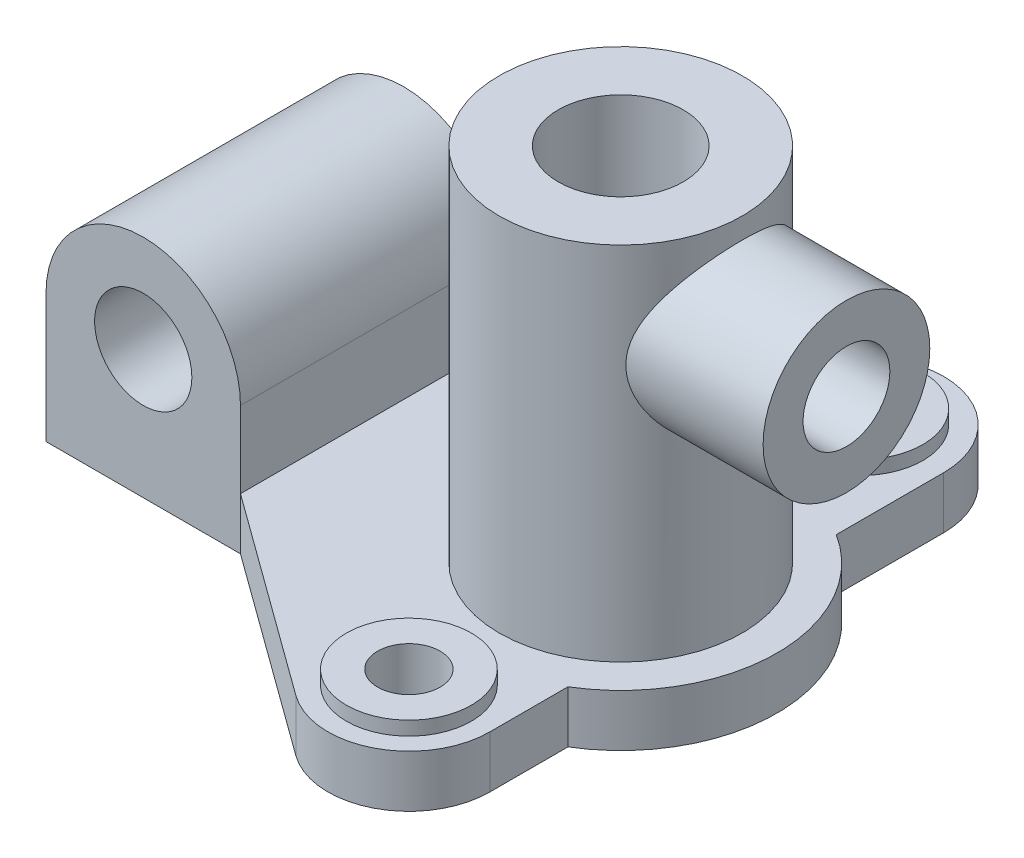
from build123d import *

# Parameters (mm, degrees)
SKETCH1_R               = 18
SKETCH1_R_2             = 35
BOSS_EXTRUDE1_DEPTH     = 15
SKETCH1_3_R             = 35
SKETCH1_3_R_2           = 18
BOSS_EXTRUDE2_DEPTH     = 119
SKETCH1_4_R             = 18
SKETCH1_4_R_2           = 9
BOSS_EXTRUDE3_DEPTH     = 19
SKETCH1_5_W             = 56
SKETCH1_5_H             = 75
BOSS_EXTRUDE4_DEPTH     = 65
CUT_EXTRUDE1_DEPTH      = 198.974745864
CUT_EXTRUDE1_DEPTH_BACK = 65
SKETCH2_R               = 14
SKETCH3_R               = 24
SKETCH3_R_2             = 12.5
BOSS_EXTRUDE5_DEPTH     = 65
SKETCH1_6_R             = 18
CUT_EXTRUDE3_DEPTH      = 263
SKETCH3_3_R             = 12.5
CUT_EXTRUDE4_DEPTH      = 263


with BuildPart() as part:
    # Sketch1 → Boss-Extrude1 (new body)
    with BuildSketch(Plane(origin=(0, 0, 0), x_dir=(1, 0, 0), z_dir=(0, 1, 0))):
        with BuildLine():
            ThreePointArc((23.30367726, -38.495955971), (44.998138968, -0.409254655), (24, 38.065732621))
            Line((24, 38.065732621), (24, 69))
            ThreePointArc((24, 69), (9.874292088, 90.874605271), (-15.87486298, 86.999686813))
            Line((-15.87486298, 86.999686813), (-72, 37.5))
            Line((-72, 37.5), (-72, -37.5))
            Line((-72, -37.5), (-13.696259751, -79.854013967))
            ThreePointArc((-13.696259751, -79.854013967), (10.58036287, -81.76336426), (23.30367726, -61))
            Line((23.30367726, -61), (23.30367726, -38.495955971))
        make_face()
        with Locations((0, -61)):
            Circle(SKETCH1_R, mode=Mode.SUBTRACT)
        Circle(SKETCH1_R_2, mode=Mode.SUBTRACT)
        with Locations((0, 69)):
            Circle(SKETCH1_R, mode=Mode.SUBTRACT)
    extrude(amount=BOSS_EXTRUDE1_DEPTH)

    # Sketch1_3 → Boss-Extrude2 (add)
    with BuildSketch(Plane(origin=(0, 0, 0), x_dir=(1, 0, 0), z_dir=(0, 1, 0))):
        Circle(SKETCH1_3_R)
        Circle(SKETCH1_3_R_2, mode=Mode.SUBTRACT)
    extrude(amount=BOSS_EXTRUDE2_DEPTH)

    # Sketch1_4 → Boss-Extrude3 (add)
    # profile 1 of 2: a face of its own
    with BuildSketch(Plane(origin=(0, 0, 0), x_dir=(1, 0, 0), z_dir=(0, 1, 0))):
        with Locations((0, 69)):
            Circle(SKETCH1_4_R)
        with Locations((0, 69)):
            Circle(SKETCH1_4_R_2, mode=Mode.SUBTRACT)
    # profile 2 of 2: a face of its own
    with BuildSketch(Plane(origin=(0, 0, 0), x_dir=(1, 0, 0), z_dir=(0, 1, 0))):
        with Locations((0, -61)):
            Circle(SKETCH1_4_R)
        with Locations((0, -61)):
            Circle(SKETCH1_4_R_2, mode=Mode.SUBTRACT)
    extrude(amount=BOSS_EXTRUDE3_DEPTH)

    # Sketch1_5 → Boss-Extrude4 (add)
    with BuildSketch(Plane(origin=(0, 0, 0), x_dir=(1, 0, 0), z_dir=(0, 1, 0))):
        with Locations((-100, 0)):
            Rectangle(SKETCH1_5_W, SKETCH1_5_H)
    extrude(amount=BOSS_EXTRUDE4_DEPTH)

    # Sketch2 → Cut-Extrude1 (cut, two sides: drawn at the far end of the back side and taken through both)
    with BuildSketch(Plane.XY.offset(-CUT_EXTRUDE1_DEPTH_BACK)):
        with BuildLine():
            Line((-128, 65), (-128, 37))
            ThreePointArc((-128, 37), (-119.798989873, 56.798989873), (-100, 65))
            Line((-100, 65), (-128, 65))
        make_face()
        with Locations((-100, 37)):
            Circle(SKETCH2_R)
        with BuildLine():
            Line((-72, 65), (-100, 65))
            ThreePointArc((-100, 65), (-80.201010127, 56.798989873), (-72, 37))
            Line((-72, 37), (-72, 65))
        make_face()
    extrude(amount=CUT_EXTRUDE1_DEPTH + CUT_EXTRUDE1_DEPTH_BACK, mode=Mode.SUBTRACT)

    # Sketch3 → Boss-Extrude5 (add)
    with BuildSketch(Plane(origin=(0, 0, 0), x_dir=(0, 0, -1), z_dir=(1, 0, 0))):
        with Locations((0, 89)):
            Circle(SKETCH3_R)
        with Locations((0, 89)):
            Circle(SKETCH3_R_2, mode=Mode.SUBTRACT)
    extrude(amount=BOSS_EXTRUDE5_DEPTH)

    # Sketch1_6 → Cut-Extrude3 (cut)
    with BuildSketch(Plane(origin=(0, 0, 0), x_dir=(1, 0, 0), z_dir=(0, 1, 0))):
        Circle(SKETCH1_6_R)
    extrude(amount=CUT_EXTRUDE3_DEPTH, mode=Mode.SUBTRACT)

    # Sketch3_3 → Cut-Extrude4 (cut)
    with BuildSketch(Plane(origin=(0, 0, 0), x_dir=(0, 0, -1), z_dir=(1, 0, 0))):
        with Locations((0, 89)):
            Circle(SKETCH3_3_R)
    extrude(amount=CUT_EXTRUDE4_DEPTH, mode=Mode.SUBTRACT)


solid = part.part
